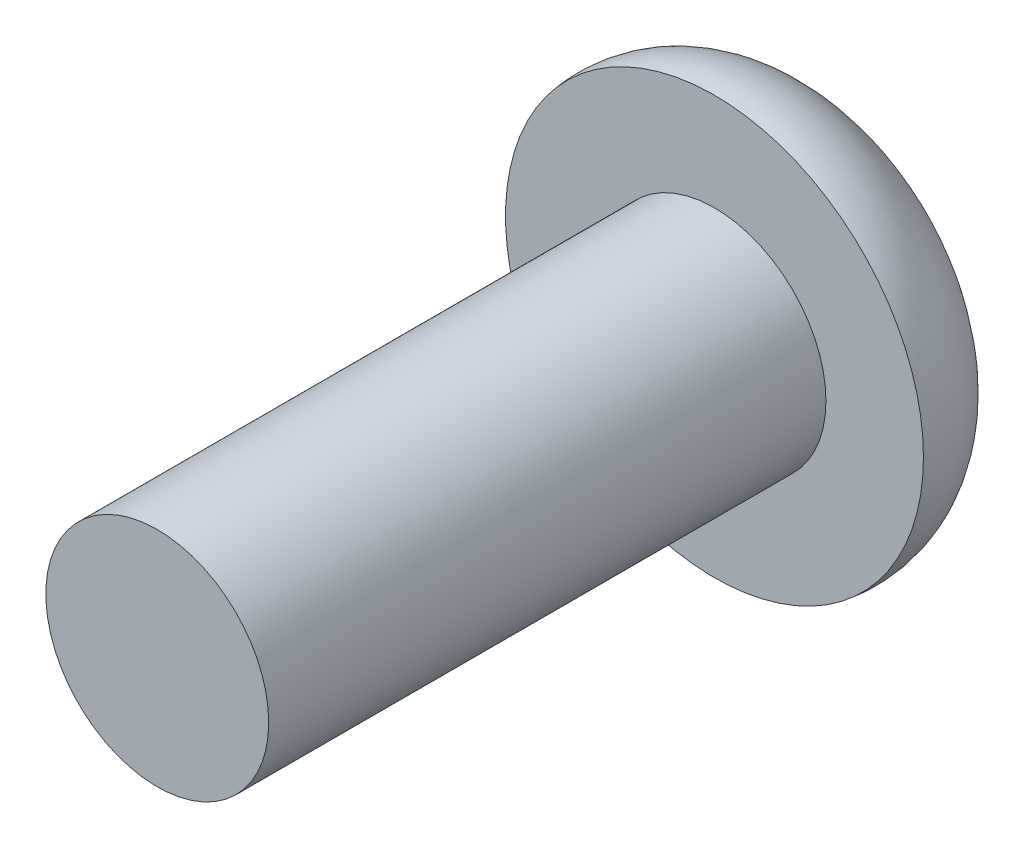
from build123d import *

# Parameters (mm, degrees)
CUT_EXTRUDE1_DEPTH = 1.8


with BuildPart() as part:
    # Sketch1 → Revolve1 (revolve)
    with BuildSketch(Plane(origin=(0, 0, 0), x_dir=(1, 0, 0), z_dir=(0, 1, 0))):
        with BuildLine():
            Line((0, 0), (-2, 0))
            Line((-2, 0), (-2, 10))
            Line((-2, 10), (-3.75, 10))
            ThreePointArc((-3.75, 10), (-3.328768227, 11.397047198), (-2, 12))
            Line((-2, 12), (0, 12))
            Line((0, 12), (0, 0))
        make_face()
    revolve(axis=Axis((0, 0, 0), (0, 0, -1)))

    # Sketch2 → Cut-Extrude1 (cut)
    with BuildSketch(Plane(origin=(0, 0, -12), x_dir=(-1, 0, 0), z_dir=(0, 0, -1))):
        Polygon((0, -1.443375673), (1.25, -0.721687836), (1.25, 0.721687836), (0, 1.443375673), (-1.25, 0.721687836), (-1.25, -0.721687836), align=None)
    extrude(amount=-CUT_EXTRUDE1_DEPTH, mode=Mode.SUBTRACT)


solid = part.part
